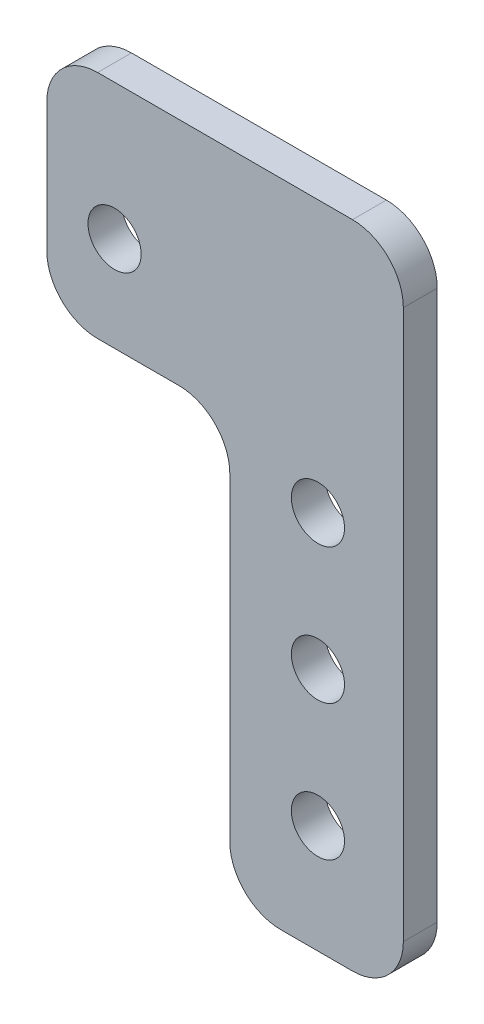
from build123d import *

# Parameters (mm, degrees)
SKETCH1_R           = 2.4892
BOSS_EXTRUDE1_DEPTH = 3.175
FILLET1_R           = 4.7625


with BuildPart() as part:
    # Sketch1 → Boss-Extrude1 (new body)
    with BuildSketch(Plane.XY):
        Polygon((28.575, -2.54), (61.976, -2.54), (61.976, -63.5), (45.72, -63.5), (45.72, -24.13), (28.575, -24.13), align=None)
        with Locations((53.975, -27.94)):
            Circle(SKETCH1_R, mode=Mode.SUBTRACT)
        with Locations((53.975, -40.64)):
            Circle(SKETCH1_R, mode=Mode.SUBTRACT)
        with Locations((53.975, -53.34)):
            Circle(SKETCH1_R, mode=Mode.SUBTRACT)
        with Locations((34.925, -15.24)):
            Circle(SKETCH1_R, mode=Mode.SUBTRACT)
    extrude(amount=BOSS_EXTRUDE1_DEPTH)

    # Fillet1
    fillet1_edges = [part.edges().sort_by_distance(p)[0] for p in [
        (61.976, -63.5, 1.5875),
        (45.72, -63.5, 1.5875),
        (45.72, -24.13, 1.5875),
        (28.575, -24.13, 1.5875),
        (28.575, -2.54, 1.5875),
        (61.976, -2.54, 1.5875),
    ]]
    fillet(fillet1_edges, radius=FILLET1_R)


solid = part.part
